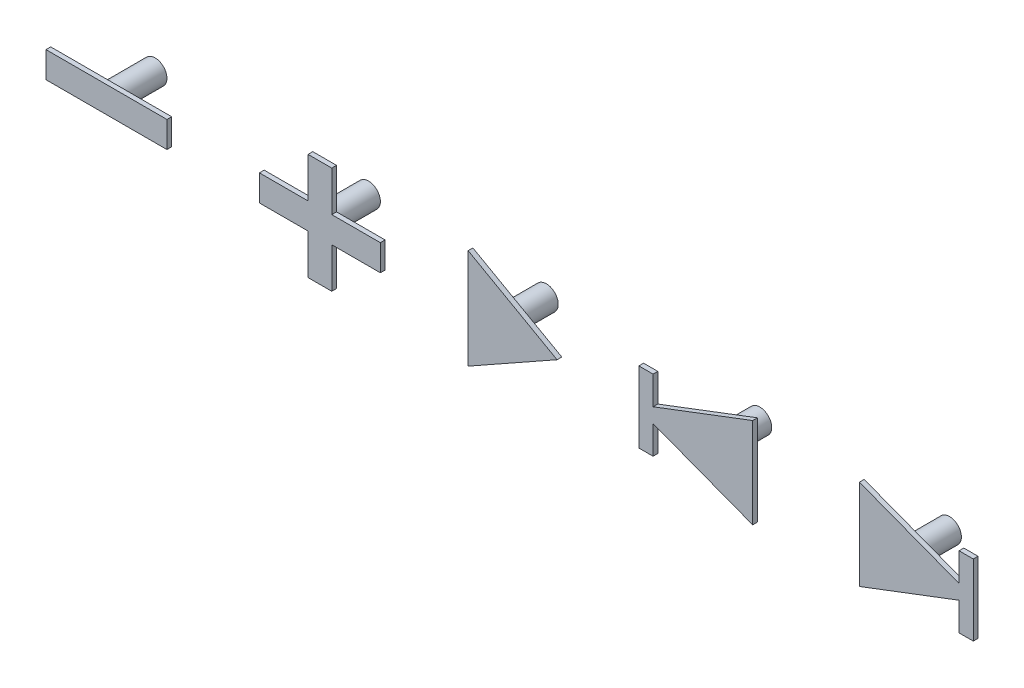
from build123d import *

# Parameters (mm, degrees)
BOSS_EXTRUDE3_DEPTH        = 0.1
BOSS_EXTRUDE3_DEPTH_BACK   = 0.3
BOSS_EXTRUDE3_2_DEPTH      = 0.1
BOSS_EXTRUDE3_2_DEPTH_BACK = 0.3
SKETCH20_W                 = 10.2
SKETCH20_H                 = 2.2
BOSS_EXTRUDE3_3_DEPTH      = 0.1
BOSS_EXTRUDE3_3_DEPTH_BACK = 0.3
BOSS_EXTRUDE3_4_DEPTH      = 0.1
BOSS_EXTRUDE3_4_DEPTH_BACK = 0.3
BOSS_EXTRUDE3_5_DEPTH      = 0.1
BOSS_EXTRUDE3_5_DEPTH_BACK = 0.3
SKETCH21_R                 = 1
BOSS_EXTRUDE4_DEPTH        = 4


with BuildPart() as part:
    # Sketch20 → Boss-Extrude3 (new body, two sides)
    with BuildSketch(Plane.XY.offset(5)) as boss_extrude3_sk:
        Polygon((-3.5, 4.21875), (-3.5, -4.21875), (4, 0), align=None)
    extrude(amount=BOSS_EXTRUDE3_DEPTH)
    extrude(boss_extrude3_sk.sketch, amount=-BOSS_EXTRUDE3_DEPTH_BACK)



with BuildPart() as body_2:
    # Sketch20 → Boss-Extrude3 2 (new body, two sides)
    with BuildSketch(Plane.XY.offset(5)) as boss_extrude3_2_sk:
        Polygon((-10.9, -1.1), (-10.9, 1.1), (-15, 1.1), (-15, 4.5), (-17, 4.5), (-17, 1.1), (-21.1, 1.1), (-21.1, -1.1), (-17, -1.1), (-17, -4.5), (-15, -4.5), (-15, -1.1), align=None)
    extrude(amount=BOSS_EXTRUDE3_2_DEPTH)
    extrude(boss_extrude3_2_sk.sketch, amount=-BOSS_EXTRUDE3_2_DEPTH_BACK)


with BuildPart() as body_3:
    # Sketch20 → Boss-Extrude3 3 (new body, two sides)
    with BuildSketch(Plane.XY.offset(5)) as boss_extrude3_3_sk:
        with Locations((-34, 0)):
            Rectangle(SKETCH20_W, SKETCH20_H)
    extrude(amount=BOSS_EXTRUDE3_3_DEPTH)
    extrude(boss_extrude3_3_sk.sketch, amount=-BOSS_EXTRUDE3_3_DEPTH_BACK)


with BuildPart() as body_4:
    # Sketch20 → Boss-Extrude3 4 (new body, two sides)
    with BuildSketch(Plane.XY.offset(5)) as boss_extrude3_4_sk:
        Polygon((10.9, 3), (10.9, -3), (12.1, -3), (12.1, -0.61511422), (20.5, -3.809837878), (20.5, 3.809837878), (12.1, 0.61511422), (12.1, 3), align=None)
    extrude(amount=BOSS_EXTRUDE3_4_DEPTH)
    extrude(boss_extrude3_4_sk.sketch, amount=-BOSS_EXTRUDE3_4_DEPTH_BACK)


with BuildPart() as body_5:
    # Sketch20 → Boss-Extrude3 5 (new body, two sides)
    with BuildSketch(Plane.XY.offset(5)) as boss_extrude3_5_sk:
        Polygon((29.5, 3.809837878), (29.5, -3.809837878), (37.9, -0.61511422), (37.9, -3), (39.1, -3), (39.1, 3), (37.9, 3), (37.9, 0.61511422), align=None)
    extrude(amount=BOSS_EXTRUDE3_5_DEPTH)
    extrude(boss_extrude3_5_sk.sketch, amount=-BOSS_EXTRUDE3_5_DEPTH_BACK)


with BuildPart() as part_1:
    add(part.part)

    add(body_2.part)  # Boss-Extrude4 merges body 2

    add(body_3.part)  # Boss-Extrude4 merges body 3

    add(body_4.part)  # Boss-Extrude4 merges body 4

    add(body_5.part)  # Boss-Extrude4 merges body 5
    # Sketch21 → Boss-Extrude4 (add)
    with BuildSketch(Plane.XY.offset(5)):
        with Locations((-1, 0)):
            Circle(SKETCH21_R)
        with Locations((-16, 0)):
            Circle(SKETCH21_R)
        with Locations((-34, 0)):
            Circle(SKETCH21_R)
        with Locations((17, 0)):
            Circle(SKETCH21_R)
        with Locations((33, 0)):
            Circle(SKETCH21_R)
    extrude(amount=-BOSS_EXTRUDE4_DEPTH)


solid = part_1.part
